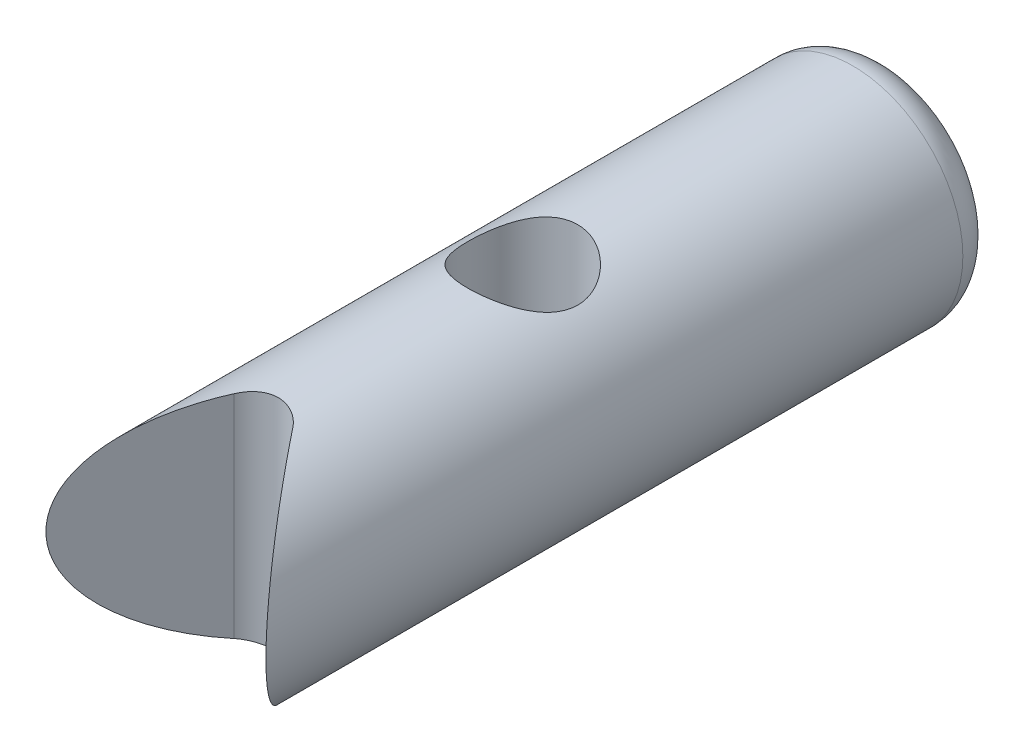
from build123d import *

# Parameters (mm, degrees)
CROQUIS1_R                 = 3
SALIENTE_EXTRUIR2_DEPTH    = 20
CROQUIS2_R                 = 1.5
CORTAR_EXTRUIR1_DEPTH      = 4
CORTAR_EXTRUIR1_DEPTH_BACK = 4
REDONDEO7_R                = 1


with BuildPart() as part:
    # Croquis1 → Saliente-Extruir2 (new body)
    with BuildSketch(Plane.XY):
        Circle(CROQUIS1_R)
    extrude(amount=SALIENTE_EXTRUIR2_DEPTH)

    # Croquis2 → Cortar-Extruir1 (cut, two sides)
    with BuildSketch(Plane(origin=(0, 0, 0), x_dir=(1, 0, 0), z_dir=(0, 1, 0))) as cortar_extruir1_sk:
        with Locations((0, -10)):
            Circle(CROQUIS2_R)
        Polygon((-3, -20), (0, -16), (3, -20), align=None)
    extrude(amount=CORTAR_EXTRUIR1_DEPTH, mode=Mode.SUBTRACT)
    extrude(cortar_extruir1_sk.sketch, amount=-CORTAR_EXTRUIR1_DEPTH_BACK, mode=Mode.SUBTRACT)

    # Redondeo7
    redondeo7_edges = [part.edges().sort_by_distance(p)[0] for p in [
        (-3, 0, 0),
        (0, 0, 16),
    ]]
    fillet(redondeo7_edges, radius=REDONDEO7_R)


solid = part.part
